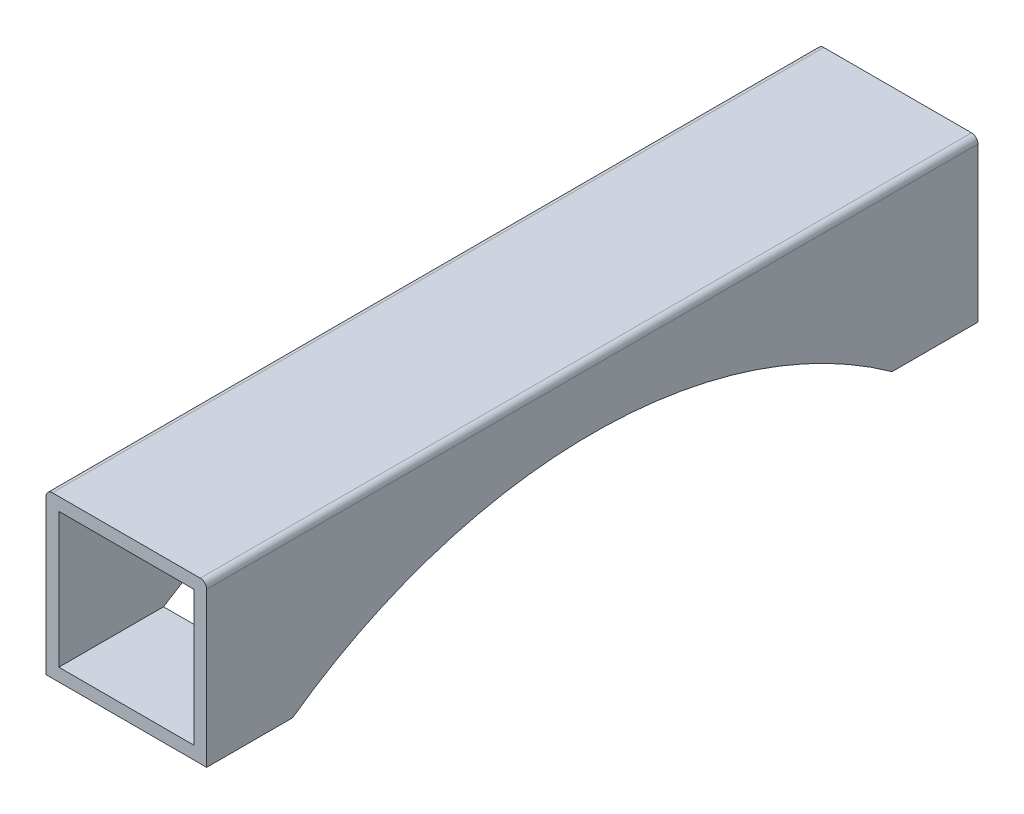
from build123d import *

# Parameters (mm, degrees)
EXTRUDE_1_DEPTH      = 60
EXTRUDE_1_DEPTH_BACK = 60
SKETCH_1_W           = 21
SKETCH_1_H           = 21
CUT_EXTRUDE_1_DEPTH  = 67.191011474


with BuildPart() as part:
    # Эскиз1 → Бобышка-Вытянуть1 (new, two sides: drawn at the far end of the back side and taken through both)
    with BuildSketch(Plane.XY.offset(-EXTRUDE_1_DEPTH_BACK)):
        with BuildLine():
            Line((-12.5, -12.5), (12.5, -12.5))
            Line((12.5, -12.5), (12.5, 11.5))
            ThreePointArc((12.5, 11.5), (12.207106781, 12.207106781), (11.5, 12.5))
            Line((11.5, 12.5), (-11.5, 12.5))
            ThreePointArc((-11.5, 12.5), (-12.207106781, 12.207106781), (-12.5, 11.5))
            Line((-12.5, 11.5), (-12.5, -12.5))
        make_face()
        Rectangle(SKETCH_1_W, SKETCH_1_H, mode=Mode.SUBTRACT)
    extrude(amount=EXTRUDE_1_DEPTH + EXTRUDE_1_DEPTH_BACK)

    # Эскиз2 → Вырез-Вытянуть1 (cut, through all)
    with BuildSketch(Plane(origin=(12.5, 0, 0), x_dir=(0, 0, -1), z_dir=(1, 0, 0))):
        with BuildLine():
            Line((-232.745226472, -146.030996161), (-46.636895265, -12.5))
            ThreePointArc((-46.636895265, -12.5), (0, 2.5), (46.636895265, -12.5))
            Line((46.636895265, -12.5), (232.745226472, -146.030996161))
            Line((232.745226472, -146.030996161), (232.745226472, -604.143811438))
            Line((232.745226472, -604.143811438), (-232.745226472, -604.143811438))
            Line((-232.745226472, -604.143811438), (-232.745226472, -146.030996161))
        make_face()
    extrude(amount=-CUT_EXTRUDE_1_DEPTH, mode=Mode.SUBTRACT)


solid = part.part
